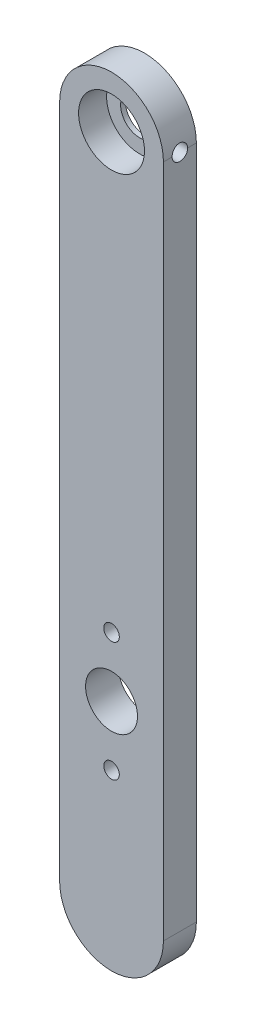
from build123d import *

# Parameters (mm, degrees)
SALIENTE_EXTRUIR1_DEPTH = 6.35
CROQUIS2_R              = 6.35
CORTAR_EXTRUIR1_DEPTH   = 5.4
CROQUIS3_R              = 3.65
CORTAR_EXTRUIR2_DEPTH   = 5.4
CROQUIS4_R              = 5
CROQUIS4_R_2            = 1.5
CORTAR_EXTRUIR3_DEPTH   = 76.929720795
CROQUIS5_R              = 1.5
CORTAR_EXTRUIR4_DEPTH   = 10


with BuildPart() as part:
    # Croquis1 → Saliente-Extruir1 (new body)
    with BuildSketch(Plane.XY):
        with BuildLine():
            Line((10, 65), (10, -65))
            ThreePointArc((10, -65), (0, -75), (-10, -65))
            Line((-10, -65), (-10, 65))
            ThreePointArc((-10, 65), (0, 75), (10, 65))
        make_face()
    extrude(amount=SALIENTE_EXTRUIR1_DEPTH)

    # Croquis2 → Cortar-Extruir1 (cut)
    with BuildSketch(Plane.XY.offset(6.35)):
        with Locations((0, 65)):
            Circle(CROQUIS2_R)
    extrude(amount=-CORTAR_EXTRUIR1_DEPTH, mode=Mode.SUBTRACT)

    # Croquis3 → Cortar-Extruir2 (cut)
    with BuildSketch(Plane.XY.offset(0.95)):
        with Locations((0, 65)):
            Circle(CROQUIS3_R)
    extrude(amount=-CORTAR_EXTRUIR2_DEPTH, mode=Mode.SUBTRACT)

    # Croquis4 → Cortar-Extruir3 (cut, through all)
    with BuildSketch(Plane.XY.offset(6.35)):
        with Locations((0, -30)):
            Circle(CROQUIS4_R)
        with Locations((0, -18.5)):
            Circle(CROQUIS4_R_2)
        with Locations((0, -41.5)):
            Circle(CROQUIS4_R_2)
    extrude(amount=-CORTAR_EXTRUIR3_DEPTH, mode=Mode.SUBTRACT)

    # Croquis5 → Cortar-Extruir4 (cut)
    with BuildSketch(Plane(origin=(10, 0, 0), x_dir=(0, 0, -1), z_dir=(1, 0, 0))):
        with Locations((-3.175, 65)):
            Circle(CROQUIS5_R)
    extrude(amount=-CORTAR_EXTRUIR4_DEPTH, mode=Mode.SUBTRACT)


solid = part.part
